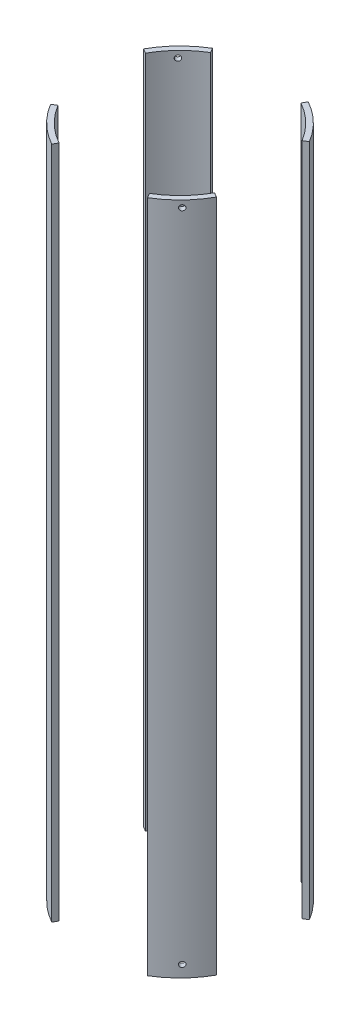
from build123d import *

# Parameters (mm, degrees)
SKETCH2_R               = 88.9
SKETCH2_R_2             = 83.82
BOSS_EXTRUDE1_DEPTH     = 317.5
CUT_EXTRUDE1_DEPTH      = 318.5
CUT_EXTRUDE1_DEPTH_BACK = 318.5
SKETCH5_R               = 2.54
BOLT_HOLES_DEPTH        = 29.911624556
BOLT_PATTERN_COUNT      = 4


with BuildPart() as part:
    # Sketch2 → Boss-Extrude1 (new body, symmetric)
    with BuildSketch(Plane(origin=(0, 0, 0), x_dir=(1, 0, 0), z_dir=(0, 1, 0))):
        Circle(SKETCH2_R)
        Circle(SKETCH2_R_2, mode=Mode.SUBTRACT)
    extrude(amount=BOSS_EXTRUDE1_DEPTH, both=True)

    # Sketch3 → Cut-Extrude1 (cut, two sides)
    with BuildSketch(Plane(origin=(0, 0, 0), x_dir=(1, 0, 0), z_dir=(0, 1, 0))) as cut_extrude1_sk:
        Polygon((169.661755759, -94.300371224), (0, 0), (169.661755759, 101.677593364), align=None)
        Polygon((0, 0), (53.900027233, 96.974944394), (-58.116685864, 96.974944394), align=None)
        Polygon((-123.741299607, 68.777140945), (-123.741299607, -74.157652604), (0, 0), align=None)
        Polygon((-65.840936026, -118.45858783), (0, 0), (70.991745134, -118.45858783), align=None)
    extrude(amount=CUT_EXTRUDE1_DEPTH, mode=Mode.SUBTRACT)
    extrude(cut_extrude1_sk.sketch, amount=-CUT_EXTRUDE1_DEPTH_BACK, mode=Mode.SUBTRACT)

    # Sketch5 → Bolt holes (cut, through all)
    with BuildSketch(Plane(origin=(-56.309218645, 0, 58.175814955), x_dir=(-0.718540152, 0, -0.695485478), z_dir=(0.695485478, 0, -0.718540152))):
        with Locations((-0.02278764, 311.15)):
            Circle(SKETCH5_R)
        with Locations((-0.02278764, -306.3875)):
            Circle(SKETCH5_R)
    bolt_holes = extrude(amount=-BOLT_HOLES_DEPTH, mode=Mode.SUBTRACT)

    # Bolt pattern: Bolt holes ×4 about axis
    bolt_pattern_axis = Axis((0, 317.5, 0), (0, 1, 0))
    for i in range(1, BOLT_PATTERN_COUNT):
        add(bolt_holes.rotate(bolt_pattern_axis, i * 360 / BOLT_PATTERN_COUNT), mode=Mode.SUBTRACT)


solid = part.part
